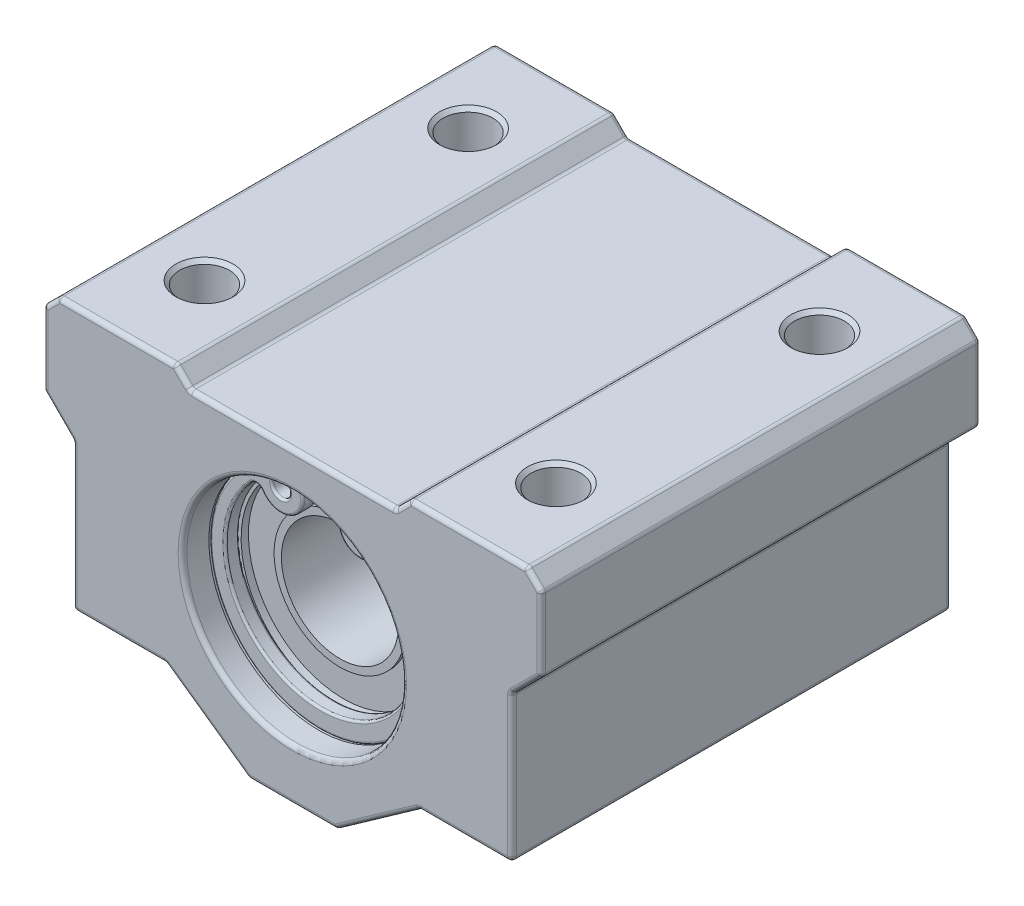
from build123d import *

# Parameters (mm, degrees)
SCHIZZO1_R                    = 7.5
ESTRUSIONE_ESTRUSIONE1_DEPTH  = 15
FORO_PER_VITE_M4_1_D          = 3.4
RIPETIZIONE_A_L1_COUNT        = 2
RIPETIZIONE_A_L1_PITCH        = 24
RIPETIZIONE_A_L1_COUNT_DIR2   = 2
RIPETIZIONE_A_L1_PITCH_DIR2   = 18
SMUSSO1_SIZE                  = 0.25
SMUSSO2_SIZE                  = 0.5
RACCORDO1_R                   = 0.3
SCHIZZO8_R                    = 4
TAGLIO_ESTRUSIONE2_DEPTH      = 16.0000001
TAGLIO_ESTRUSIONE2_DEPTH_BACK = 16.0000001
TAGLIO_ESTRUSIONE1_START      = 12.1
SCHIZZO7_R                    = 7.85
TAGLIO_ESTRUSIONE1_DEPTH      = 1.1
ESTRUSIONE_ESTRUSIONE2_START  = 12.1
SCHIZZO9_R                    = 0.6
ESTRUSIONE_ESTRUSIONE2_DEPTH  = 1
RIPETIZIONE_A_L2_COUNT        = 2
RIPETIZIONE_A_L2_PITCH        = 25.2
RACCORDO4_R                   = 0.15
RACCORDO5_R                   = 0.15


with BuildPart() as part:
    # Schizzo1 → Estrusione-Estrusione1 (new body, symmetric)
    with BuildSketch(Plane.XY):
        Polygon((3, -11), (8.666666667, -7), (15, -7), (15, 3), (17, 5), (17, 10), (16, 11), (8, 11), (7, 10), (-7, 10), (-8, 11), (-16, 11), (-17, 10), (-17, 5), (-15, 3), (-15, -7), (-8.666666667, -7), (-3, -11), align=None)
        Circle(SCHIZZO1_R, mode=Mode.SUBTRACT)
    extrude(amount=ESTRUSIONE_ESTRUSIONE1_DEPTH, both=True)

    # Foro per Vite M4-1 (through all)
    with Locations(Plane(origin=(0, 11, 0), x_dir=(1, 0, 0), z_dir=(0, 1, 0))):
        with Locations((-12, 9)):
            foro_per_vite_m4_1 = Hole(FORO_PER_VITE_M4_1_D / 2)

    # Ripetizione a L1: Foro per Vite M4-1 2 × 2
    with Locations(*[(i * RIPETIZIONE_A_L1_PITCH, 0, j * RIPETIZIONE_A_L1_PITCH_DIR2) for i in range(RIPETIZIONE_A_L1_COUNT) for j in range(RIPETIZIONE_A_L1_COUNT_DIR2) if (i, j) != (0, 0)]):
        add(foro_per_vite_m4_1, mode=Mode.SUBTRACT)

    # Smusso1
    smusso1_edges = [part.edges().sort_by_distance(p)[0] for p in [
        (-10.3, 11, -9),
        (-10.3, 11, 9),
        (13.7, 11, -9),
        (13.7, 11, 9),
    ]]
    chamfer(smusso1_edges, length=SMUSSO1_SIZE)

    # Smusso2
    smusso2_edges = [part.edges().sort_by_distance(p)[0] for p in [
        (-10.3, -7, -9),
        (-10.3, -7, 9),
        (13.7, -7, -9),
        (13.7, -7, 9),
    ]]
    chamfer(smusso2_edges, length=SMUSSO2_SIZE)

    # Schizzo6 → Rivoluzione1 (revolve)
    with BuildSketch(Plane(origin=(0, 0, 0), x_dir=(0, 0, -1), z_dir=(1, 0, 0))):
        Polygon((-12, 6.5), (-11.5, 6.5), (-11.5, 4.5), (-11.75, 4.5), (-11.75, 0), (11.75, 0), (11.75, 4.5), (11.5, 4.5), (11.5, 6.5), (12, 6.5), (12, 7.5), (-12, 7.5), align=None)
    revolve(axis=Axis((0, 0, 20), (0, 0, -1)))

    # Raccordo1
    raccordo1_edges = [part.edges().sort_by_distance(p)[0] for p in [
        (11.833333333, -7, 15),
        (15, -2, 15),
        (-5.833333333, -9, -15),
        (16, 4, 15),
        (-11.833333333, -7, -15),
        (-15, -2, -15),
        (-16, 4, -15),
        (-17, 7.5, -15),
        (-16.5, 10.5, -15),
        (-12, 11, -15),
        (-7.5, 10.5, -15),
        (0, 10, -15),
        (17, 7.5, 15),
        (7.5, 10.5, -15),
        (12, 11, -15),
        (16.5, 10.5, -15),
        (17, 7.5, -15),
        (16, 4, -15),
        (15, -2, -15),
        (11.833333333, -7, -15),
        (16.5, 10.5, 15),
        (5.833333333, -9, -15),
        (0, -11, -15),
        (12, 11, 15),
        (7.5, 10.5, 15),
        (-3, -11, 0),
        (-8.666666667, -7, 0),
        (-15, -7, 0),
        (-15, 3, 0),
        (-17, 5, 0),
        (-17, 10, 0),
        (-16, 11, 0),
        (-8, 11, 0),
        (-7, 10, 0),
        (7, 10, 0),
        (8, 11, 0),
        (16, 11, 0),
        (17, 10, 0),
        (17, 5, 0),
        (15, 3, 0),
        (15, -7, 0),
        (8.666666667, -7, 0),
        (3, -11, 0),
        (0, 10, 15),
        (-7.5, 10.5, 15),
        (-12, 11, 15),
        (0, -11, 15),
        (-16.5, 10.5, 15),
        (-7.5, 0, -15),
        (-17, 7.5, 15),
        (-7.5, 0, 15),
        (-16, 4, 15),
        (-15, -2, 15),
        (-11.833333333, -7, 15),
        (-5.833333333, -9, 15),
        (5.833333333, -9, 15),
    ]]
    fillet(raccordo1_edges, radius=RACCORDO1_R)

    # Schizzo8 → Taglio-Estrusione2 (cut, two sides)
    with BuildSketch(Plane.XY) as taglio_estrusione2_sk:
        Circle(SCHIZZO8_R)
    extrude(amount=TAGLIO_ESTRUSIONE2_DEPTH, mode=Mode.SUBTRACT)
    extrude(taglio_estrusione2_sk.sketch, amount=-TAGLIO_ESTRUSIONE2_DEPTH_BACK, mode=Mode.SUBTRACT)

    # Schizzo7 → Taglio-Estrusione1 (cut)
    with BuildSketch(Plane.XY.offset(TAGLIO_ESTRUSIONE1_START)):
        Circle(SCHIZZO7_R)
    taglio_estrusione1 = extrude(amount=TAGLIO_ESTRUSIONE1_DEPTH, mode=Mode.SUBTRACT)

    # Specchia1: Taglio-Estrusione1 across plane
    add(taglio_estrusione1.mirror(Plane.XY), mode=Mode.SUBTRACT)


with BuildPart() as body_2:
    # Schizzo9 → Estrusione-Estrusione2 (new body)
    with BuildSketch(Plane.XY.offset(ESTRUSIONE_ESTRUSIONE2_START)):
        with BuildLine():
            ThreePointArc((-3.368793489, 6.75675443), (0, -7.55), (3.368793489, 6.75675443))
            ThreePointArc((3.368793489, 6.75675443), (1.254348915, 5.012422945), (3.965778539, 4.610281696))
            ThreePointArc((3.965778539, 4.610281696), (4.341737039, 4.840124939), (4.7535285, 4.683279463))
            ThreePointArc((4.7535285, 4.683279463), (0, -6.25), (-4.7535285, 4.683279463))
            ThreePointArc((-4.7535285, 4.683279463), (-4.341737039, 4.840124939), (-3.965778539, 4.610281696))
            ThreePointArc((-3.965778539, 4.610281696), (-1.254348915, 5.012422945), (-3.368793489, 6.75675443))
        make_face()
        with Locations((-2.699496769, 5.414352888)):
            Circle(SCHIZZO9_R, mode=Mode.SUBTRACT)
        with Locations((2.699496769, 5.414352888)):
            Circle(SCHIZZO9_R, mode=Mode.SUBTRACT)
    estrusione_estrusione2 = extrude(amount=ESTRUSIONE_ESTRUSIONE2_DEPTH)

    # Raccordo4
    raccordo4_edges = [body_2.edges().sort_by_distance(p)[0] for p in [
        (0, -6.25, 13.1),
        (-4.341737039, 4.840124939, 13.1),
        (-1.254348915, 5.012422945, 13.1),
        (-3.299496769, 5.414352888, 12.1),
        (-3.299496769, 5.414352888, 13.1),
        (0, -7.55, 13.1),
        (2.099496769, 5.414352888, 12.1),
        (2.099496769, 5.414352888, 13.1),
        (1.254348915, 5.012422945, 13.1),
        (0, -7.55, 12.1),
        (-1.254348915, 5.012422945, 12.1),
        (-4.341737039, 4.840124939, 12.1),
        (4.341737039, 4.840124939, 13.1),
        (0, -6.25, 12.1),
        (4.341737039, 4.840124939, 12.1),
        (1.254348915, 5.012422945, 12.1),
    ]]
    fillet(raccordo4_edges, radius=RACCORDO4_R)


with BuildPart() as ripetizione_a_l2_1:
    # Ripetizione a L2: Estrusione-Estrusione2 ×2
    with Locations(*[(0, 0, -i * RIPETIZIONE_A_L2_PITCH) for i in range(1, RIPETIZIONE_A_L2_COUNT)]):
        add(estrusione_estrusione2)

    # Raccordo5
    raccordo5_edges = [ripetizione_a_l2_1.edges().sort_by_distance(p)[0] for p in [
        (0, -6.25, -12.1),
        (-4.341737039, 4.840124939, -12.1),
        (-1.254348915, 5.012422945, -12.1),
        (-3.299496769, 5.414352888, -13.1),
        (-3.299496769, 5.414352888, -12.1),
        (0, -7.55, -12.1),
        (2.099496769, 5.414352888, -13.1),
        (2.099496769, 5.414352888, -12.1),
        (1.254348915, 5.012422945, -12.1),
        (0, -7.55, -13.1),
        (-1.254348915, 5.012422945, -13.1),
        (-4.341737039, 4.840124939, -13.1),
        (4.341737039, 4.840124939, -12.1),
        (0, -6.25, -13.1),
        (4.341737039, 4.840124939, -13.1),
        (1.254348915, 5.012422945, -13.1),
    ]]
    fillet(raccordo5_edges, radius=RACCORDO5_R)


solid = Compound([part.part, body_2.part, ripetizione_a_l2_1.part])
